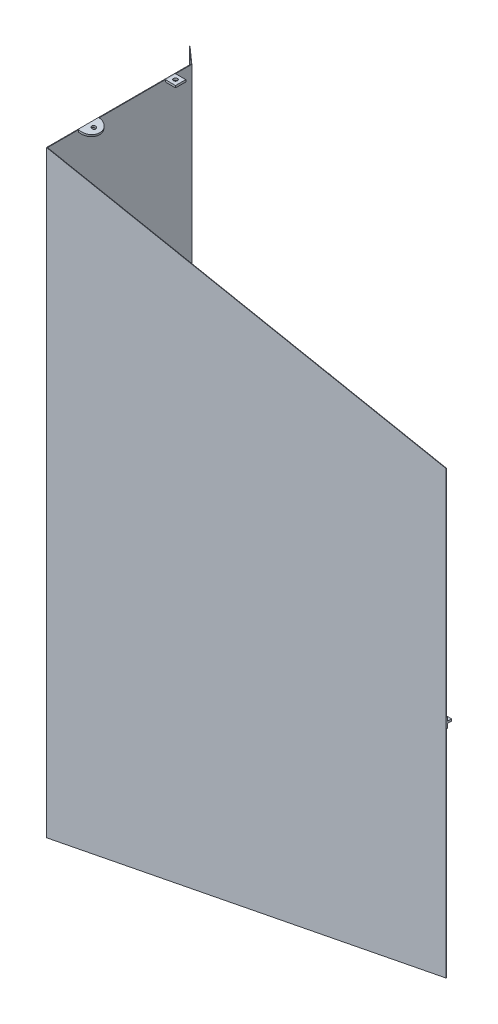
from build123d import *

# Parameters (mm, degrees)
WYCI_GNI_CIE_CIENKA_CIANKA1_DEPTH      = 400
WYCI_GNI_CIE_CIENKA_CIANKA1_DEPTH_BACK = 400
DODANIE_WYCI_GNI_CIE2_DEPTH            = 2
SZKIC6_W                               = 389.49
SZKIC6_H                               = 5
WYCI_GNI_CIE_CIENKA_CIANKA2_DEPTH      = 1
WYCI_GNI_CIE_CIENKA_CIANKA2_DEPTH_BACK = 1
SZKIC6_2_W                             = 389.49
SZKIC6_2_H                             = 1
WYCI_GNI_CIE_CIENKA_CIANKA3_DEPTH      = 5
WYCI_GNI_CIE_CIENKA_CIANKA3_DEPTH_BACK = 5
SZKIC7_R                               = 2
WYTNIJ_WYCI_GNI_CIE1_DEPTH             = 10
SZKIC9_W                               = 10
SZKIC9_H                               = 2
WYCI_GNI_CIE_CIENKA_CIANKA4_DEPTH      = 10
SZKIC10_R                              = 2
WYTNIJ_WYCI_GNI_CIE2_DEPTH             = 10
SKETCH1_R                              = 4
BOSS_EXTRUDE1_DEPTH                    = 12


with BuildPart() as part:
    # Szkic1 → Wyci_gni_cie-cienka _cianka1 (new, two sides)
    with BuildSketch(Plane(origin=(0, 0, 0), x_dir=(1, 0, 0), z_dir=(0, 1, 0))) as wyci_gni_cie_cienka_cianka1_sk:
        Polygon((956.950680953, -465.228422764), (970.58269303, -477.059346089), (970.58269303, -617.999346089), (1360.07269303, -617.999346089), (1360.07269303, -618.499346089), (970.08269303, -618.499346089), (970.08269303, -477.287451692), (956.622954545, -465.606040827), align=None)
    extrude(amount=WYCI_GNI_CIE_CIENKA_CIANKA1_DEPTH)
    extrude(wyci_gni_cie_cienka_cianka1_sk.sketch, amount=-WYCI_GNI_CIE_CIENKA_CIANKA1_DEPTH_BACK)

    # Ci_cie powierzchni_1
    split(bisect_by=Plane(origin=(90.906039695, 464.075841363, 0), x_dir=(-0.9813493581662637, 0.19223276834780917, 0), z_dir=(0.19223276834780917, 0.9813493581662637, 0)), keep=Keep.BOTTOM)

    # Ci_cie powierzchni_2
    split(bisect_by=Plane(origin=(90.906039695, -464.075841363, 0), x_dir=(-0.9813493581662637, -0.19223276834780917, 0), z_dir=(-0.19223276834780917, 0.9813493581662637, 0)), keep=Keep.TOP)

    # Szkic4 → Dodanie-wyci_gni_cie2 (add)
    with BuildSketch(Plane(origin=(90.906039695, -464.075841363, 0), x_dir=(-0.9813493581662637, -0.19223276834780914, 0), z_dir=(0.19223276834780914, -0.9813493581662637, 0))):
        with BuildLine():
            Line((-896.394995334, -587.669895838), (-896.394995334, -567.646267832))
            ThreePointArc((-896.394995334, -567.646267832), (-907.43844862, -577.658081835), (-896.394995334, -587.669895838))
        make_face()
    dodanie_wyci_gni_cie2 = extrude(amount=-DODANIE_WYCI_GNI_CIE2_DEPTH)

    # Szkic6 → Wyci_gni_cie-cienka _cianka2 (add, two sides)
    with BuildSketch(Plane(origin=(0, 0, 0), x_dir=(1, 0, 0), z_dir=(0, 1, 0))) as wyci_gni_cie_cienka_cianka2_sk:
        with Locations((1165.32769303, -615.499346089)):
            Rectangle(SZKIC6_W, SZKIC6_H)
    extrude(amount=WYCI_GNI_CIE_CIENKA_CIANKA2_DEPTH)
    extrude(wyci_gni_cie_cienka_cianka2_sk.sketch, amount=-WYCI_GNI_CIE_CIENKA_CIANKA2_DEPTH_BACK)

    # Szkic6_2 → Wyci_gni_cie-cienka _cianka3 (add, two sides)
    with BuildSketch(Plane(origin=(0, 0, 0), x_dir=(1, 0, 0), z_dir=(0, 1, 0))) as wyci_gni_cie_cienka_cianka3_sk:
        with Locations((1165.32769303, -617.499346089)):
            Rectangle(SZKIC6_2_W, SZKIC6_2_H)
    extrude(amount=WYCI_GNI_CIE_CIENKA_CIANKA3_DEPTH)
    extrude(wyci_gni_cie_cienka_cianka3_sk.sketch, amount=-WYCI_GNI_CIE_CIENKA_CIANKA3_DEPTH_BACK)

    # Szkic7 → Wytnij-wyci_gni_cie1 (cut)
    with BuildSketch(Plane(origin=(90.521574159, -462.113142647, 0), x_dir=(0.9813493581662637, 0.19223276834780917, 0), z_dir=(-0.19223276834780914, 0.9813493581662636, 0))):
        with Locations(Location((901.117736464, -577.428231407, 0), (0, 0, 180))):
            Circle(SZKIC7_R)
    wytnij_wyci_gni_cie1 = extrude(amount=-WYTNIJ_WYCI_GNI_CIE1_DEPTH, mode=Mode.SUBTRACT)

    # Lustro1: Dodanie-wyci_gni_cie2, Wytnij-wyci_gni_cie1 across plane
    add(dodanie_wyci_gni_cie2.mirror(Plane.ZX))
    add(wytnij_wyci_gni_cie1.mirror(Plane.ZX), mode=Mode.SUBTRACT)

    # Szkic9 → Wyci_gni_cie-cienka _cianka4 (add)
    with BuildSketch(Plane(origin=(970.58269303, 0, 0), x_dir=(0, 0, -1), z_dir=(1, 0, 0))):
        with Locations((-497.999346089, -290.759349877)):
            Rectangle(SZKIC9_W, SZKIC9_H)
    wyci_gni_cie_cienka_cianka4 = extrude(amount=WYCI_GNI_CIE_CIENKA_CIANKA4_DEPTH)

    # Szkic10 → Wytnij-wyci_gni_cie2 (cut)
    with BuildSketch(Plane(origin=(0, -289.759349877, 0), x_dir=(1, 0, 0), z_dir=(0, 1, 0))):
        with Locations(Location((975.58269303, -497.999346089, 0), (0, 0, 270))):
            Circle(SZKIC10_R)
    wytnij_wyci_gni_cie2 = extrude(amount=-WYTNIJ_WYCI_GNI_CIE2_DEPTH, mode=Mode.SUBTRACT)

    # Sketch1 → Boss-Extrude1 (add)
    with BuildSketch(Plane(origin=(0, 0, 617.999346089), x_dir=(-1, 0, 0), z_dir=(0, 0, -1))):
        with Locations(Location((-1233.504191335, -222.034079566, 0), (0, 0, 180))):
            Circle(SKETCH1_R)
    boss_extrude1 = extrude(amount=BOSS_EXTRUDE1_DEPTH)

    # Lustro2: Wyci_gni_cie-cienka _cianka4, Wytnij-wyci_gni_cie2, Boss-Extrude1 across plane
    add(wyci_gni_cie_cienka_cianka4.mirror(Plane.ZX))
    add(wytnij_wyci_gni_cie2.mirror(Plane.ZX), mode=Mode.SUBTRACT)
    add(boss_extrude1.mirror(Plane.ZX))


solid = part.part
